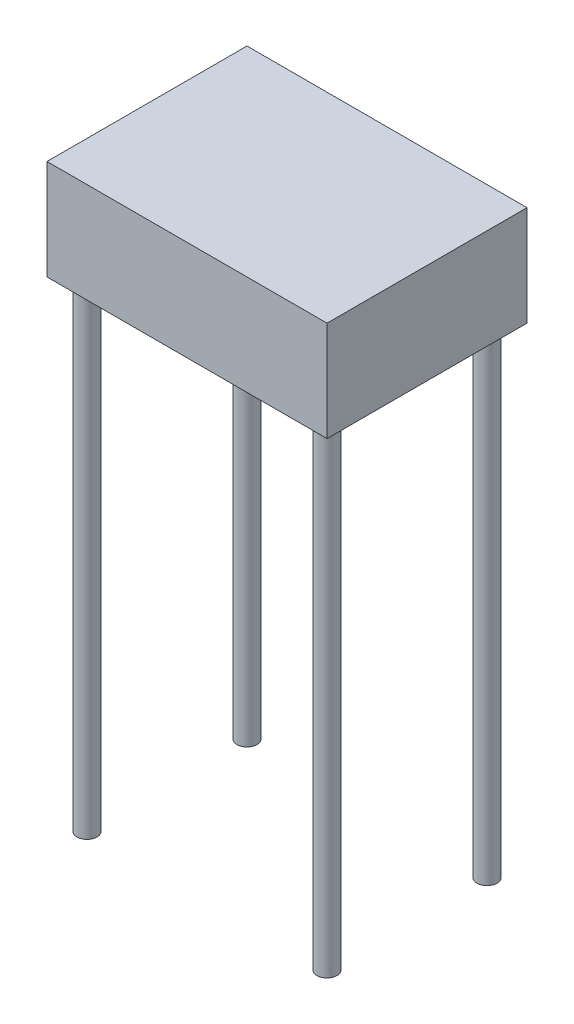
from build123d import *

# Parameters (mm, degrees)
SKETCH_1_R        = 25
EXTRUDE_1_DEPTH   = 1200
EXTRUDE_1_2_DEPTH = 1200
EXTRUDE_1_3_DEPTH = 1200
EXTRUDE_1_4_DEPTH = 1200
SKETCH_2_W        = 700
SKETCH_2_H        = 500
EXTRUDE_2_DEPTH   = 250


with BuildPart() as part:
    # 草图1 → 凸台-拉伸1 (new body)
    with BuildSketch(Plane(origin=(0, 0, 0), x_dir=(1, 0, 0), z_dir=(0, 1, 0))):
        with Locations((-300, 200)):
            Circle(SKETCH_1_R)
    extrude(amount=EXTRUDE_1_DEPTH)



with BuildPart() as body_2:
    # 草图1 → Extrude 1 2 (new body)
    with BuildSketch(Plane(origin=(0, 0, 0), x_dir=(1, 0, 0), z_dir=(0, 1, 0))):
        with Locations((300, 200)):
            Circle(SKETCH_1_R)
    extrude(amount=EXTRUDE_1_2_DEPTH)


with BuildPart() as body_3:
    # 草图1 → Extrude 1 3 (new body)
    with BuildSketch(Plane(origin=(0, 0, 0), x_dir=(1, 0, 0), z_dir=(0, 1, 0))):
        with Locations((300, -200)):
            Circle(SKETCH_1_R)
    extrude(amount=EXTRUDE_1_3_DEPTH)


with BuildPart() as body_4:
    # 草图1 → Extrude 1 4 (new body)
    with BuildSketch(Plane(origin=(0, 0, 0), x_dir=(1, 0, 0), z_dir=(0, 1, 0))):
        with Locations((-300, -200)):
            Circle(SKETCH_1_R)
    extrude(amount=EXTRUDE_1_4_DEPTH)


with BuildPart() as part_1:
    add(part.part)

    add(body_2.part)  # 凸台-拉伸2 merges body 2

    add(body_3.part)  # 凸台-拉伸2 merges body 3

    add(body_4.part)  # 凸台-拉伸2 merges body 4
    # 草图2 → 凸台-拉伸2 (add)
    with BuildSketch(Plane(origin=(0, 1200, 0), x_dir=(1, 0, 0), z_dir=(0, 1, 0))):
        Rectangle(SKETCH_2_W, SKETCH_2_H)
    extrude(amount=EXTRUDE_2_DEPTH)


solid = part_1.part
